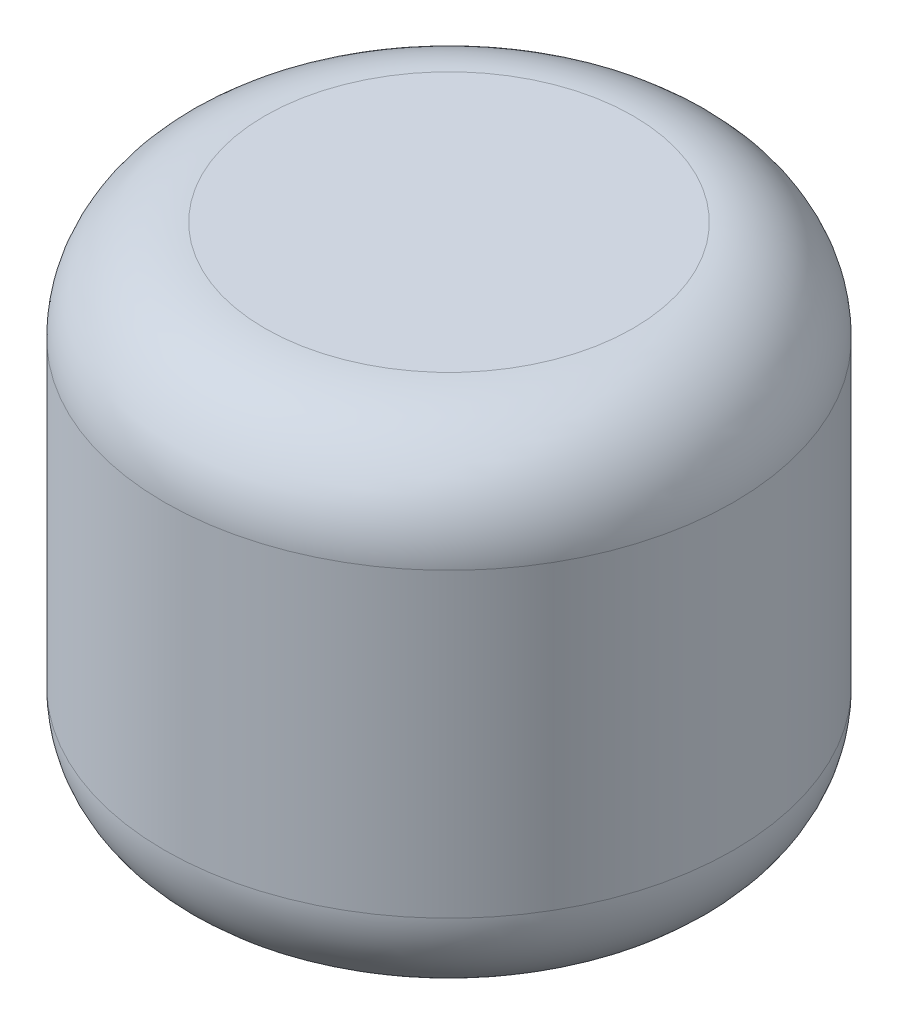
from build123d import *

# Parameters (mm, degrees)
SKETCH_1_R          = 8.5
EXTRUDE_1_DEPTH     = 15
SKETCH_2_R          = 3.5
CUT_EXTRUDE_1_DEPTH = 10
FILLET_1_R          = 3


with BuildPart() as part:
    # Эскиз1 → Бобышка-Вытянуть1 (new body)
    with BuildSketch(Plane(origin=(0, 0, 0), x_dir=(1, 0, 0), z_dir=(0, 1, 0))):
        Circle(SKETCH_1_R)
    extrude(amount=EXTRUDE_1_DEPTH)

    # Эскиз2 → Вырез-Вытянуть1 (cut)
    with BuildSketch(Plane.XZ):
        Circle(SKETCH_2_R)
    extrude(amount=-CUT_EXTRUDE_1_DEPTH, mode=Mode.SUBTRACT)

    # Скругление1
    fillet_1_edges = [part.edges().sort_by_distance(p)[0] for p in [
        (-8.5, 0, 0),
        (-8.5, 15, 0),
    ]]
    fillet(fillet_1_edges, radius=FILLET_1_R)


solid = part.part
